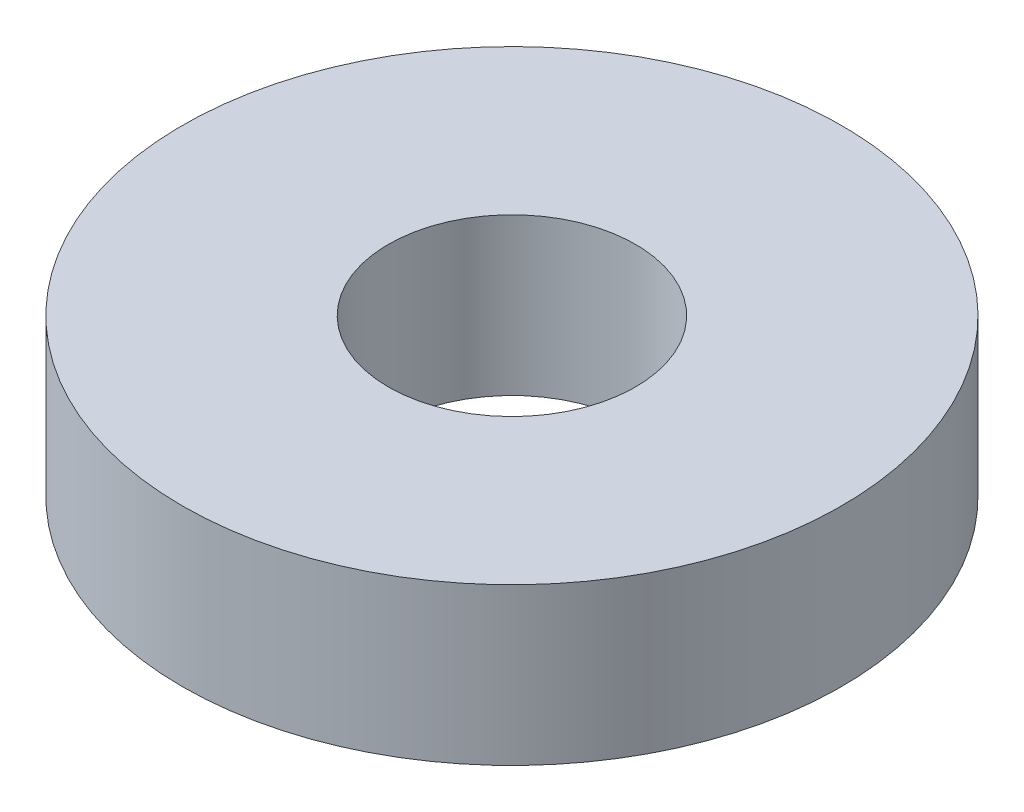
from build123d import *

# Parameters (mm, degrees)
SKETCH1_R           = 4
SKETCH1_R_2         = 1.5
BOSS_EXTRUDE1_DEPTH = 1.9


with BuildPart() as part:
    # Sketch1 → Boss-Extrude1 (new body)
    with BuildSketch(Plane(origin=(0, 0, 0), x_dir=(1, 0, 0), z_dir=(0, 1, 0))):
        Circle(SKETCH1_R)
        Circle(SKETCH1_R_2, mode=Mode.SUBTRACT)
    extrude(amount=BOSS_EXTRUDE1_DEPTH)


solid = part.part
